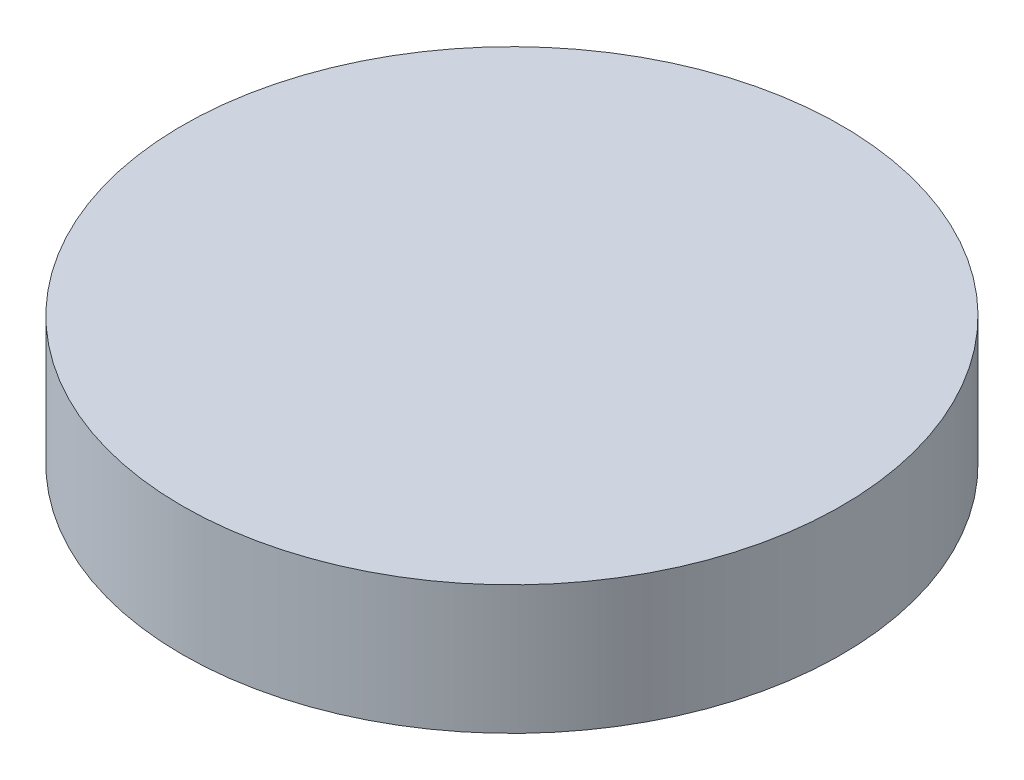
from build123d import *

# Parameters (mm, degrees)
SKETCH_1_R      = 6.25
EXTRUDE_1_DEPTH = 2.44


with BuildPart() as part:
    # 草图1 → 凸台-拉伸1 (new body)
    with BuildSketch(Plane(origin=(0, 0, 0), x_dir=(1, 0, 0), z_dir=(0, 1, 0))):
        with Locations(Location((0, 0, 0), (0, 0, 270))):  # turned: the seam where the file's is
            Circle(SKETCH_1_R)
    extrude(amount=EXTRUDE_1_DEPTH)


solid = part.part
